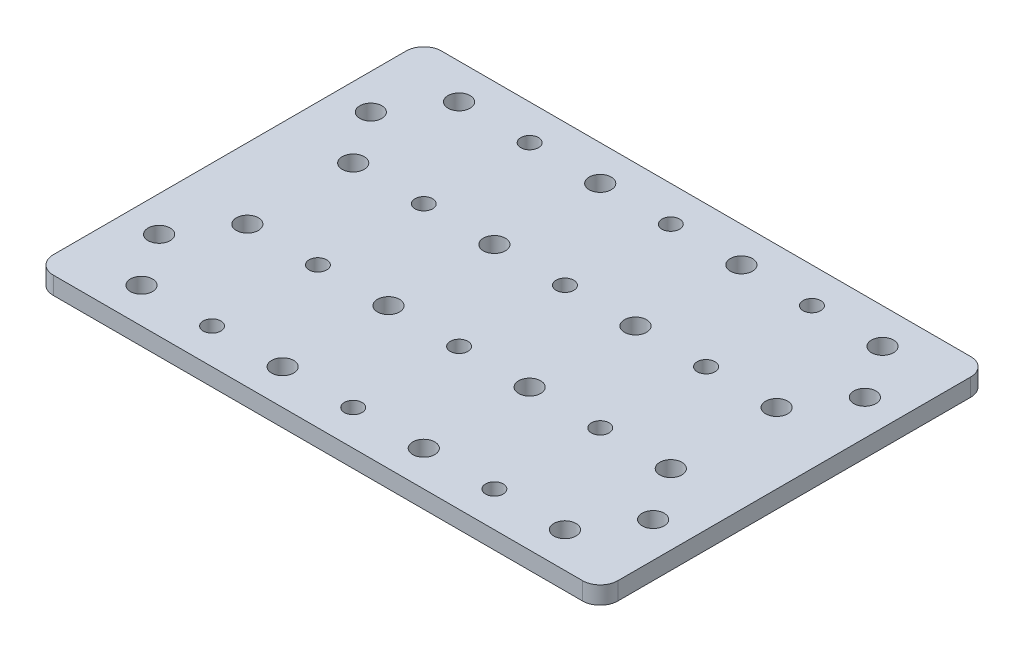
from build123d import *

# Parameters (mm, degrees)
SKETCH3_W                      = 203.2
SKETCH3_H                      = 6.35
BOSS_EXTRUDE1_DEPTH            = 76.2
BOSS_EXTRUDE1_DEPTH_BACK       = 76.2
F_3_8_16_TAPPED_HOLE1_D        = 7.9375
F_3_8_16_TAPPED_HOLE1_DEPTH    = 6.35
F_1_4_0_2500_DOWEL_HOLE1_D     = 6.35
F_1_4_0_2500_DOWEL_HOLE1_DEPTH = 6.35
F_3_8_16_TAPPED_HOLE2_D        = 7.9375
F_3_8_16_TAPPED_HOLE2_DEPTH    = 6.35
SKETCH10_W                     = 203.2
SKETCH10_H                     = 12.7
CUT_EXTRUDE1_DEPTH             = 7.35
FILLET1_R                      = 6.35


with BuildPart() as part:
    # Sketch3 → Boss-Extrude1 (new body, two sides)
    with BuildSketch(Plane.XY) as boss_extrude1_sk:
        Rectangle(SKETCH3_W, SKETCH3_H)
    extrude(amount=BOSS_EXTRUDE1_DEPTH)
    extrude(boss_extrude1_sk.sketch, amount=-BOSS_EXTRUDE1_DEPTH_BACK)

    # 3/8-16 Tapped Hole1
    with Locations(Plane(origin=(0, 3.175, 0), x_dir=(1, 0, 0), z_dir=(0, 1, 0))):
        with Locations((-76.2, -63.5), (-25.4, -63.5), (25.4, -63.5), (76.2, -63.5), (-25.4, -25.4), (25.4, -25.4), (76.2, -25.4), (-25.4, 12.7), (25.4, 12.7), (76.2, 12.7), (-25.4, 50.8), (25.4, 50.8), (76.2, 50.8), (-76.2, -25.4), (-76.2, 12.7), (-76.2, 50.8)):
            Hole(F_3_8_16_TAPPED_HOLE1_D / 2, depth=F_3_8_16_TAPPED_HOLE1_DEPTH)

    # 1/4 (0.2500) Dowel Hole1
    with Locations(Plane(origin=(0, 3.175, 0), x_dir=(1, 0, 0), z_dir=(0, 1, 0))):
        with Locations((-50.8, -63.5), (0, -63.5), (50.8, -63.5), (0, -25.4), (50.8, -25.4), (0, 12.7), (50.8, 12.7), (0, 50.8), (50.8, 50.8), (-50.8, -25.4), (-50.8, 12.7), (-50.8, 50.8)):
            Hole(F_1_4_0_2500_DOWEL_HOLE1_D / 2, depth=F_1_4_0_2500_DOWEL_HOLE1_DEPTH)

    # 3/8-16 Tapped Hole2
    with Locations(Plane(origin=(0, 3.175, 0), x_dir=(1, 0, 0), z_dir=(0, 1, 0))):
        with Locations((-88.9, 31.75), (-88.9, -44.45), (88.9, -44.45), (88.9, 31.75)):
            Hole(F_3_8_16_TAPPED_HOLE2_D / 2, depth=F_3_8_16_TAPPED_HOLE2_DEPTH)

    # Sketch10 → Cut-Extrude1 (cut, through all)
    with BuildSketch(Plane(origin=(0, 3.175, 0), x_dir=(1, 0, 0), z_dir=(0, 1, 0))):
        with Locations((0, 69.85)):
            Rectangle(SKETCH10_W, SKETCH10_H)
    extrude(amount=-CUT_EXTRUDE1_DEPTH, mode=Mode.SUBTRACT)

    # Fillet1
    fillet1_edges = [part.edges().sort_by_distance(p)[0] for p in [
        (101.6, 0, 76.2),
        (-101.6, 0, -63.5),
        (101.6, 0, -63.5),
        (-101.6, 0, 76.2),
    ]]
    fillet(fillet1_edges, radius=FILLET1_R)


solid = part.part
